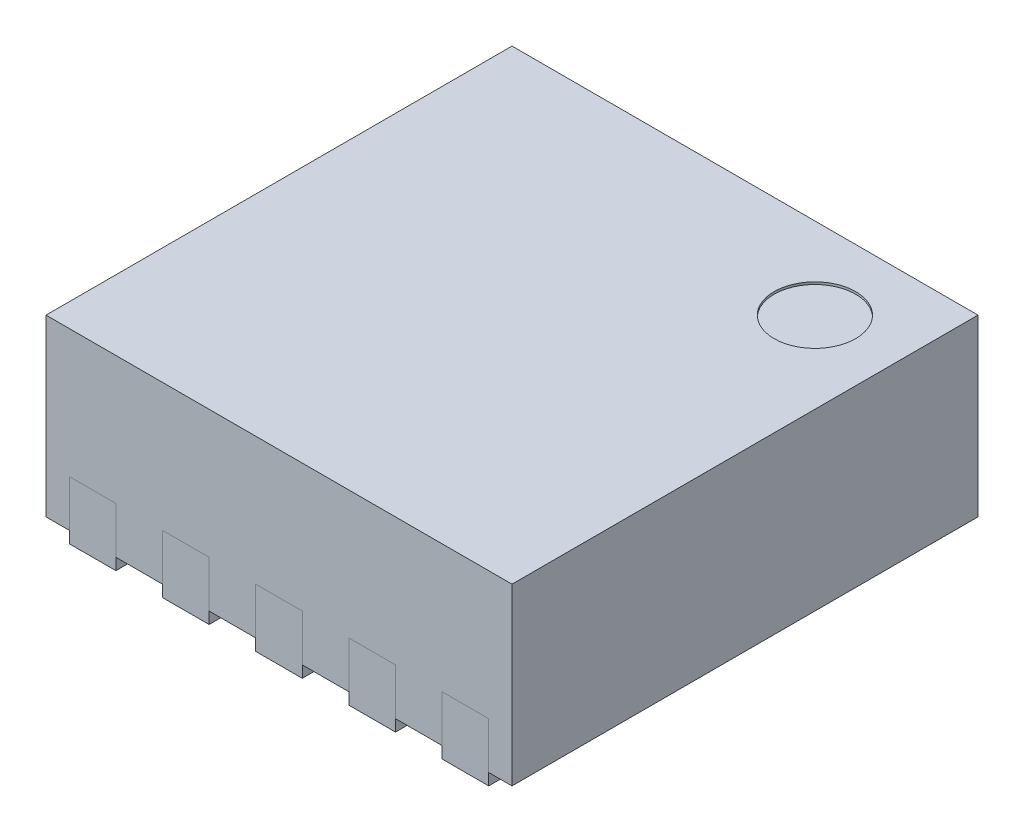
from build123d import *

# Parameters (mm, degrees)
SKETCH1_W              = 2
SKETCH1_H              = 2
BOSS_EXTRUDE1_DEPTH    = 0.75
SKETCH2_W              = 0.2
SKETCH2_H              = 0.3
CUT_EXTRUDE1_DEPTH     = 0.2
SKETCH3_W              = 0.2
SKETCH3_H              = 0.3
BOSS_EXTRUDE2_DEPTH    = 0.25
BOSS_EXTRUDE2_2_DEPTH  = 0.25
BOSS_EXTRUDE2_3_DEPTH  = 0.25
BOSS_EXTRUDE2_4_DEPTH  = 0.25
BOSS_EXTRUDE2_5_DEPTH  = 0.25
BOSS_EXTRUDE2_6_DEPTH  = 0.25
BOSS_EXTRUDE2_7_DEPTH  = 0.25
BOSS_EXTRUDE2_8_DEPTH  = 0.25
BOSS_EXTRUDE2_9_DEPTH  = 0.25
BOSS_EXTRUDE2_10_DEPTH = 0.25
BOSS_EXTRUDE2_11_DEPTH = 0.25
SKETCH4_R              = 0.175
CUT_EXTRUDE2_DEPTH     = 0.01


with BuildPart() as part:
    # Sketch1 → Boss-Extrude1 (new body)
    with BuildSketch(Plane(origin=(0, 0, 0), x_dir=(1, 0, 0), z_dir=(0, 1, 0))):
        Rectangle(SKETCH1_W, SKETCH1_H)
    extrude(amount=BOSS_EXTRUDE1_DEPTH)

    # Sketch2 → Cut-Extrude1 (cut)
    with BuildSketch(Plane.XZ):
        Polygon((0.75, 0.45), (-0.75, 0.45), (-0.75, -0.45), (0.55, -0.45), (0.75, -0.25), align=None)
        with Locations((-0.8, 0.85)):
            Rectangle(SKETCH2_W, SKETCH2_H)
        with Locations((-0.4, 0.85)):
            Rectangle(SKETCH2_W, SKETCH2_H)
        with Locations((0, 0.85)):
            Rectangle(SKETCH2_W, SKETCH2_H)
        with Locations((0.4, 0.85)):
            Rectangle(SKETCH2_W, SKETCH2_H)
        with Locations((0.8, 0.85)):
            Rectangle(SKETCH2_W, SKETCH2_H)
        with Locations((0.8, -0.85)):
            Rectangle(SKETCH2_W, SKETCH2_H)
        with Locations((0.4, -0.85)):
            Rectangle(SKETCH2_W, SKETCH2_H)
        with Locations((0, -0.85)):
            Rectangle(SKETCH2_W, SKETCH2_H)
        with Locations((-0.4, -0.85)):
            Rectangle(SKETCH2_W, SKETCH2_H)
        with Locations((-0.8, -0.85)):
            Rectangle(SKETCH2_W, SKETCH2_H)
    extrude(amount=-CUT_EXTRUDE1_DEPTH, mode=Mode.SUBTRACT)

    # Sketch4 → Cut-Extrude2 (cut)
    with BuildSketch(Plane(origin=(0, 0.75, 0), x_dir=(1, 0, 0), z_dir=(0, 1, 0))):
        with Locations((0.65, 0.65)):
            Circle(SKETCH4_R)
    extrude(amount=-CUT_EXTRUDE2_DEPTH, mode=Mode.SUBTRACT)


with BuildPart() as body_2:
    # Sketch3 → Boss-Extrude2 (new body)
    with BuildSketch(Plane.XZ.offset(-0.2)):
        with Locations((-0.8, -0.85)):
            Rectangle(SKETCH3_W, SKETCH3_H)
    extrude(amount=BOSS_EXTRUDE2_DEPTH)


with BuildPart() as body_3:
    # Sketch3 → Boss-Extrude2 2 (new body)
    with BuildSketch(Plane.XZ.offset(-0.2)):
        with Locations((-0.4, -0.85)):
            Rectangle(SKETCH3_W, SKETCH3_H)
    extrude(amount=BOSS_EXTRUDE2_2_DEPTH)


with BuildPart() as body_4:
    # Sketch3 → Boss-Extrude2 3 (new body)
    with BuildSketch(Plane.XZ.offset(-0.2)):
        with Locations((0, -0.85)):
            Rectangle(SKETCH3_W, SKETCH3_H)
    extrude(amount=BOSS_EXTRUDE2_3_DEPTH)


with BuildPart() as body_5:
    # Sketch3 → Boss-Extrude2 4 (new body)
    with BuildSketch(Plane.XZ.offset(-0.2)):
        with Locations((0.8, -0.85)):
            Rectangle(SKETCH3_W, SKETCH3_H)
    extrude(amount=BOSS_EXTRUDE2_4_DEPTH)


with BuildPart() as body_6:
    # Sketch3 → Boss-Extrude2 5 (new body)
    with BuildSketch(Plane.XZ.offset(-0.2)):
        with Locations((0.4, -0.85)):
            Rectangle(SKETCH3_W, SKETCH3_H)
    extrude(amount=BOSS_EXTRUDE2_5_DEPTH)


with BuildPart() as body_7:
    # Sketch3 → Boss-Extrude2 6 (new body)
    with BuildSketch(Plane.XZ.offset(-0.2)):
        Polygon((0.75, 0.45), (-0.75, 0.45), (-0.75, -0.45), (0.55, -0.45), (0.75, -0.25), align=None)
    extrude(amount=BOSS_EXTRUDE2_6_DEPTH)


with BuildPart() as body_8:
    # Sketch3 → Boss-Extrude2 7 (new body)
    with BuildSketch(Plane.XZ.offset(-0.2)):
        with Locations((0.8, 0.85)):
            Rectangle(SKETCH3_W, SKETCH3_H)
    extrude(amount=BOSS_EXTRUDE2_7_DEPTH)


with BuildPart() as body_9:
    # Sketch3 → Boss-Extrude2 8 (new body)
    with BuildSketch(Plane.XZ.offset(-0.2)):
        with Locations((0.4, 0.85)):
            Rectangle(SKETCH3_W, SKETCH3_H)
    extrude(amount=BOSS_EXTRUDE2_8_DEPTH)


with BuildPart() as body_10:
    # Sketch3 → Boss-Extrude2 9 (new body)
    with BuildSketch(Plane.XZ.offset(-0.2)):
        with Locations((0, 0.85)):
            Rectangle(SKETCH3_W, SKETCH3_H)
    extrude(amount=BOSS_EXTRUDE2_9_DEPTH)


with BuildPart() as body_11:
    # Sketch3 → Boss-Extrude2 10 (new body)
    with BuildSketch(Plane.XZ.offset(-0.2)):
        with Locations((-0.4, 0.85)):
            Rectangle(SKETCH3_W, SKETCH3_H)
    extrude(amount=BOSS_EXTRUDE2_10_DEPTH)


with BuildPart() as body_12:
    # Sketch3 → Boss-Extrude2 11 (new body)
    with BuildSketch(Plane.XZ.offset(-0.2)):
        with Locations((-0.8, 0.85)):
            Rectangle(SKETCH3_W, SKETCH3_H)
    extrude(amount=BOSS_EXTRUDE2_11_DEPTH)


solid = Compound([part.part, body_2.part, body_3.part, body_4.part, body_5.part, body_6.part, body_7.part, body_8.part, body_9.part, body_10.part, body_11.part, body_12.part])
